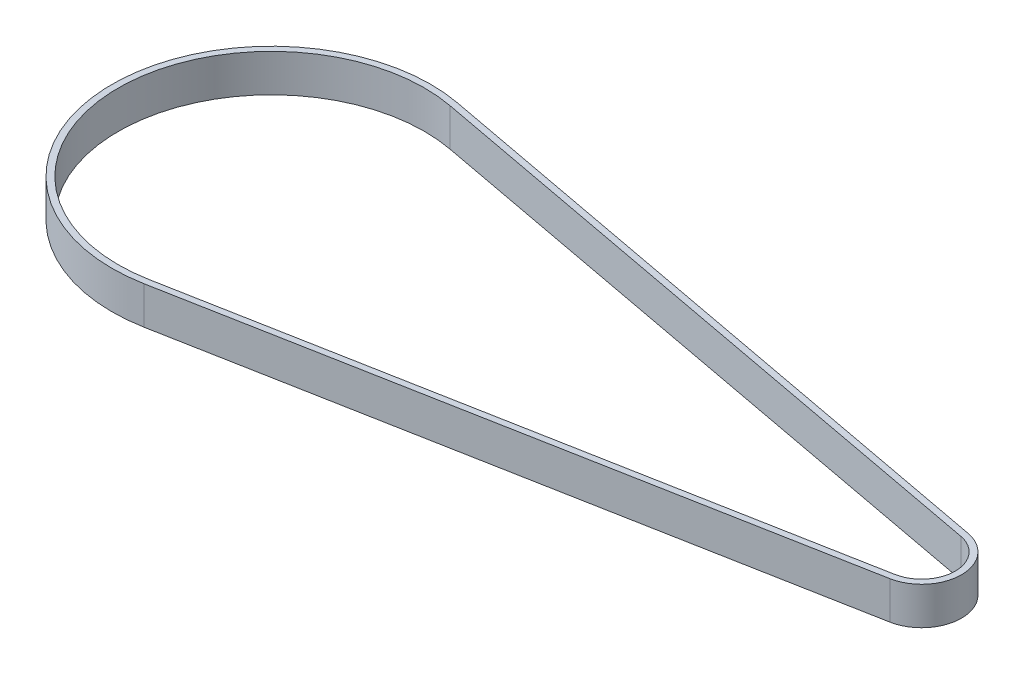
from build123d import *

# Parameters (mm, degrees)
SALIENTE_EXTRUIR1_DEPTH = 6


with BuildPart() as part:
    # Croquis1 → Saliente-Extruir1 (new body)
    with BuildSketch(Plane(origin=(0, 0, 0), x_dir=(1, 0, 0), z_dir=(0, 1, 0))):
        with BuildLine():
            Line((4.669820608, 24.967033774), (104.783855152, 6.241758444))
            ThreePointArc((104.783855152, 6.241758444), (109.9664, 0), (104.783855152, -6.241758444))
            Line((104.783855152, -6.241758444), (4.669820608, -24.967033774))
            ThreePointArc((4.669820608, -24.967033774), (-25.4, 0), (4.669820608, 24.967033774))
        make_face()
        with BuildLine():
            Line((4.485969403, 23.984079689), (104.600003947, 5.258804358))
            ThreePointArc((104.600003947, 5.258804358), (108.9664, 0), (104.600003947, -5.258804358))
            Line((104.600003947, -5.258804358), (4.485969403, -23.984079689))
            ThreePointArc((4.485969403, -23.984079689), (-24.4, 0), (4.485969403, 23.984079689))
        make_face(mode=Mode.SUBTRACT)
    extrude(amount=SALIENTE_EXTRUIR1_DEPTH)


solid = part.part
